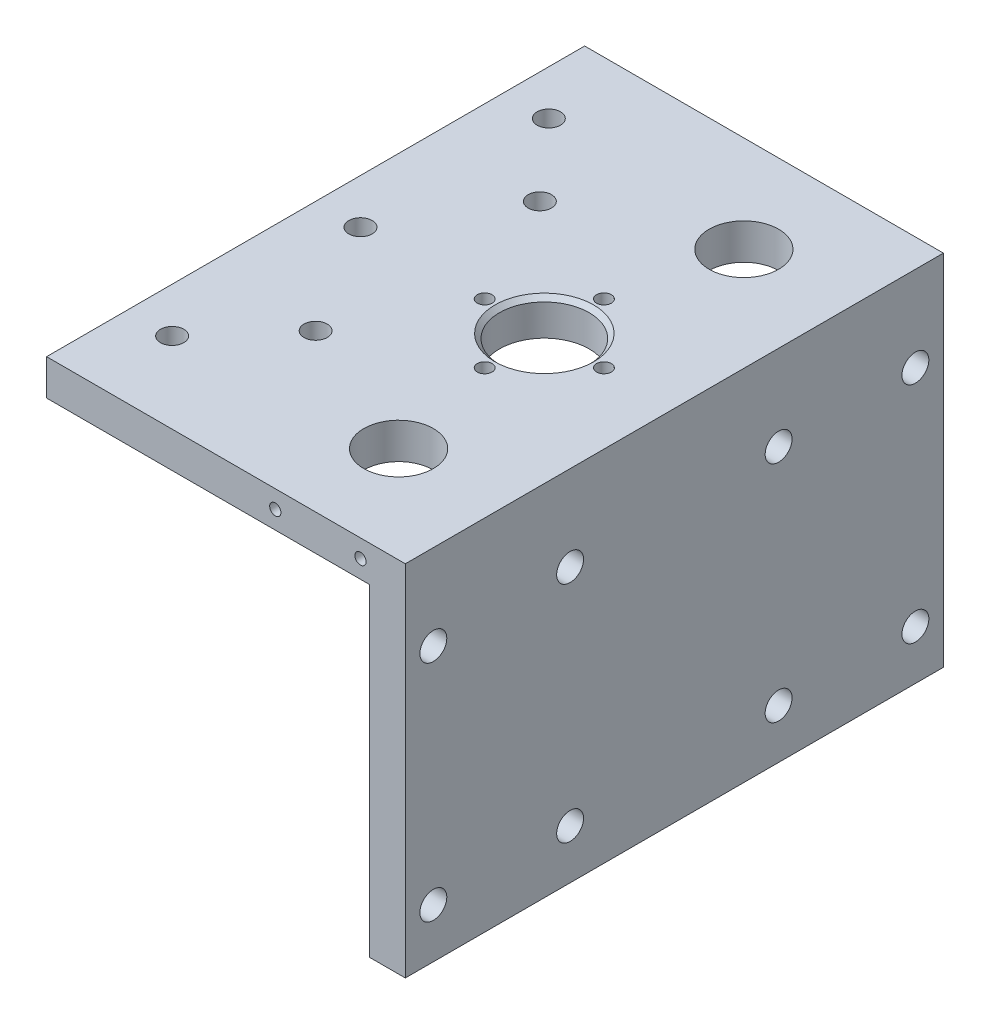
from build123d import *

# Parameters (mm, degrees)
ESTRUSIONE_ESTRUSIONE1_DEPTH = 120
TAGLIO_ESTRUSIONE2_REACH     = 82
SCHIZZO6_R                   = 7.75
TAGLIO_ESTRUSIONE3_REACH     = 82
SCHIZZO7_R                   = 10
M4_TAPPED_HOLE1_D            = 3.3
SCHIZZO12_R                  = 3
TAGLIO_ESTRUSIONE4_DEPTH     = 10
SCHIZZO14_R                  = 2.6
TAGLIO_ESTRUSIONE5_DEPTH     = 10
SMUSSO2_SIZE                 = 1
FORO_FILETTATO_M3_1_D        = 2.5
FORO_FILETTATO_M3_1_DEPTH    = 10
FORO_FILETTATO_M3_1_TIP      = 0.751075774


with BuildPart() as part:
    # Schizzo1 → Estrusione-Estrusione1 (new body)
    with BuildSketch(Plane.XY):
        Polygon((0, 0), (-80, 0), (-80, -8), (-8, -8), (-8, -80), (0, -80), align=None)
    extrude(amount=ESTRUSIONE_ESTRUSIONE1_DEPTH)

    # Schizzo6 → Taglio-Estrusione2 (cut, up to next)
    with BuildSketch(Plane(origin=(0, 0, 0), x_dir=(1, 0, 0), z_dir=(0, 1, 0)), mode=Mode.PRIVATE) as taglio_estrusione2_sk1:
        with Locations((-23, -21.5)):
            Circle(SCHIZZO6_R)
    taglio_estrusione2_tool1 = extrude(taglio_estrusione2_sk1.sketch, amount=-TAGLIO_ESTRUSIONE2_REACH, mode=Mode.PRIVATE) & part.part
    add(taglio_estrusione2_tool1.solids().sort_by_distance((-23, 0, 21.5))[0], mode=Mode.SUBTRACT)
    # Schizzo6 → Taglio-Estrusione2 (cut, up to next)
    with BuildSketch(Plane(origin=(0, 0, 0), x_dir=(1, 0, 0), z_dir=(0, 1, 0)), mode=Mode.PRIVATE) as taglio_estrusione2_sk2:
        with Locations((-23, -98.5)):
            Circle(SCHIZZO6_R)
    taglio_estrusione2_tool2 = extrude(taglio_estrusione2_sk2.sketch, amount=-TAGLIO_ESTRUSIONE2_REACH, mode=Mode.PRIVATE) & part.part
    add(taglio_estrusione2_tool2.solids().sort_by_distance((-23, 0, 98.5))[0], mode=Mode.SUBTRACT)

    # Schizzo7 → Taglio-Estrusione3 (cut, up to next)
    with BuildSketch(Plane(origin=(0, 0, 0), x_dir=(1, 0, 0), z_dir=(0, 1, 0)), mode=Mode.PRIVATE) as taglio_estrusione3_sk1:
        with Locations((-29, -60)):
            Circle(SCHIZZO7_R)
    taglio_estrusione3_tool1 = extrude(taglio_estrusione3_sk1.sketch, amount=-TAGLIO_ESTRUSIONE3_REACH, mode=Mode.PRIVATE) & part.part
    add(taglio_estrusione3_tool1.solids().sort_by_distance((-29, 0, 60))[0], mode=Mode.SUBTRACT)

    # M4 Tapped Hole1 (through all)
    with Locations(Plane(origin=(0, 0, 0), x_dir=(1, 0, 0), z_dir=(0, 1, 0))):
        with Locations((-29, -46.7), (-42.3, -60), (-29, -73.3), (-15.7, -60), (-29, -60)):
            Hole(M4_TAPPED_HOLE1_D / 2)

    # Schizzo12 → Taglio-Estrusione4 (cut)
    with BuildSketch(Plane(origin=(0, 0, 0), x_dir=(0, 0, -1), z_dir=(1, 0, 0))):
        with Locations((-113.75, -19)):
            Circle(SCHIZZO12_R)
        with Locations((-83.25, -19)):
            Circle(SCHIZZO12_R)
        with Locations((-36.75, -19)):
            Circle(SCHIZZO12_R)
        with Locations((-6.25, -19)):
            Circle(SCHIZZO12_R)
        with Locations((-83.25, -69)):
            Circle(SCHIZZO12_R)
        with Locations((-113.75, -69)):
            Circle(SCHIZZO12_R)
        with Locations((-6.25, -69)):
            Circle(SCHIZZO12_R)
        with Locations((-36.75, -69)):
            Circle(SCHIZZO12_R)
    extrude(amount=-TAGLIO_ESTRUSIONE4_DEPTH, mode=Mode.SUBTRACT)

    # Schizzo14 → Taglio-Estrusione5 (cut)
    with BuildSketch(Plane(origin=(0, 0, 0), x_dir=(1, 0, 0), z_dir=(0, 1, 0))):
        with Locations((-70, -18)):
            Circle(SCHIZZO14_R)
        with Locations((-70, -60)):
            Circle(SCHIZZO14_R)
        with Locations((-70, -102)):
            Circle(SCHIZZO14_R)
        with Locations((-55, -35)):
            Circle(SCHIZZO14_R)
        with Locations((-55, -85)):
            Circle(SCHIZZO14_R)
    extrude(amount=-TAGLIO_ESTRUSIONE5_DEPTH, mode=Mode.SUBTRACT)

    # Smusso2
    smusso2_edges = [part.edges().sort_by_distance(p)[0] for p in [
        (-39, 0, 60),
    ]]
    chamfer(smusso2_edges, length=SMUSSO2_SIZE)

    # Foro filettato M3-1
    with Locations(Plane.XY.offset(120)):
        with Locations((-10, -4), (-29, -4)):
            Hole(FORO_FILETTATO_M3_1_D / 2, depth=FORO_FILETTATO_M3_1_DEPTH)
            with Locations((0, 0, -(FORO_FILETTATO_M3_1_DEPTH + FORO_FILETTATO_M3_1_TIP / 2))):  # 118° drill point
                Cone(0, FORO_FILETTATO_M3_1_D / 2, FORO_FILETTATO_M3_1_TIP, mode=Mode.SUBTRACT)


solid = part.part
